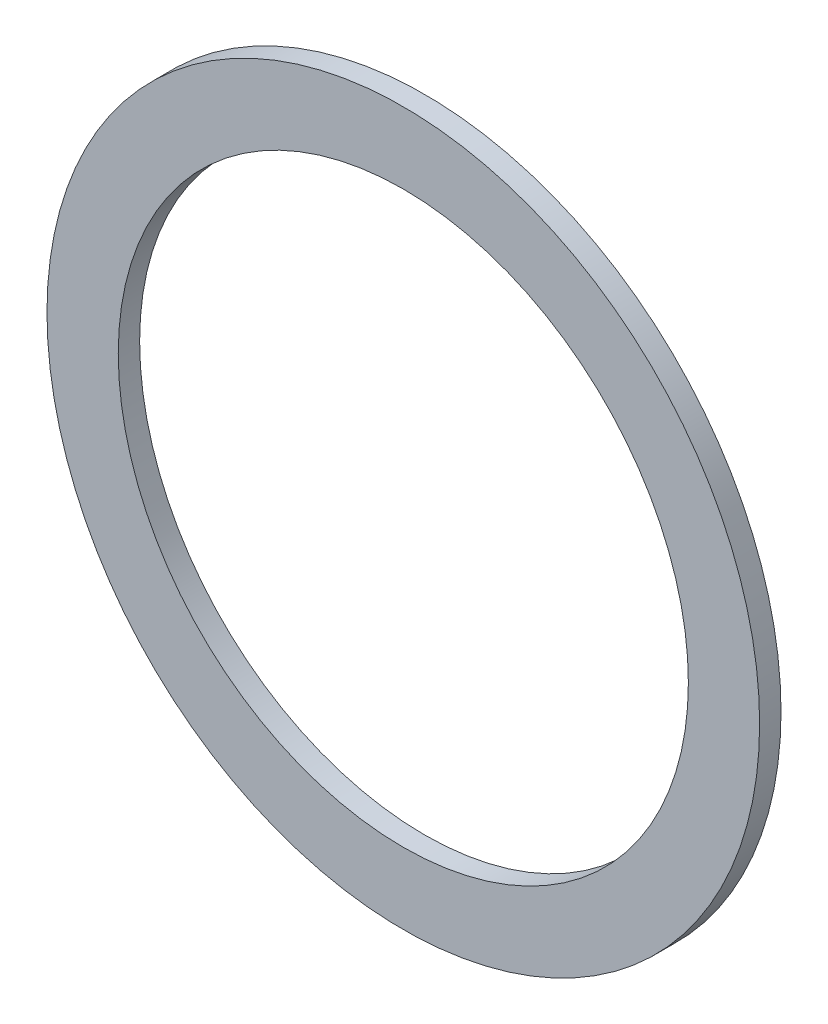
from build123d import *

# Parameters (mm, degrees)
SKETCH1_R           = 1.666666667
SKETCH1_R_2         = 1
BOSS_EXTRUDE1_DEPTH = 0.075
SKETCH2_R           = 1.869609612
SKETCH2_R_2         = 1.25
CUT_EXTRUDE1_DEPTH  = 10


with BuildPart() as part:
    # Sketch1 → Boss-Extrude1 (new body)
    with BuildSketch(Plane.XY):
        Circle(SKETCH1_R)
        Circle(SKETCH1_R_2, mode=Mode.SUBTRACT)
    extrude(amount=BOSS_EXTRUDE1_DEPTH)

    # Sketch2 → Cut-Extrude1 (cut)
    with BuildSketch(Plane.XY.offset(0.075)):
        Circle(SKETCH2_R)
        Circle(SKETCH2_R_2, mode=Mode.SUBTRACT)
    extrude(amount=-CUT_EXTRUDE1_DEPTH, mode=Mode.SUBTRACT)


solid = part.part
